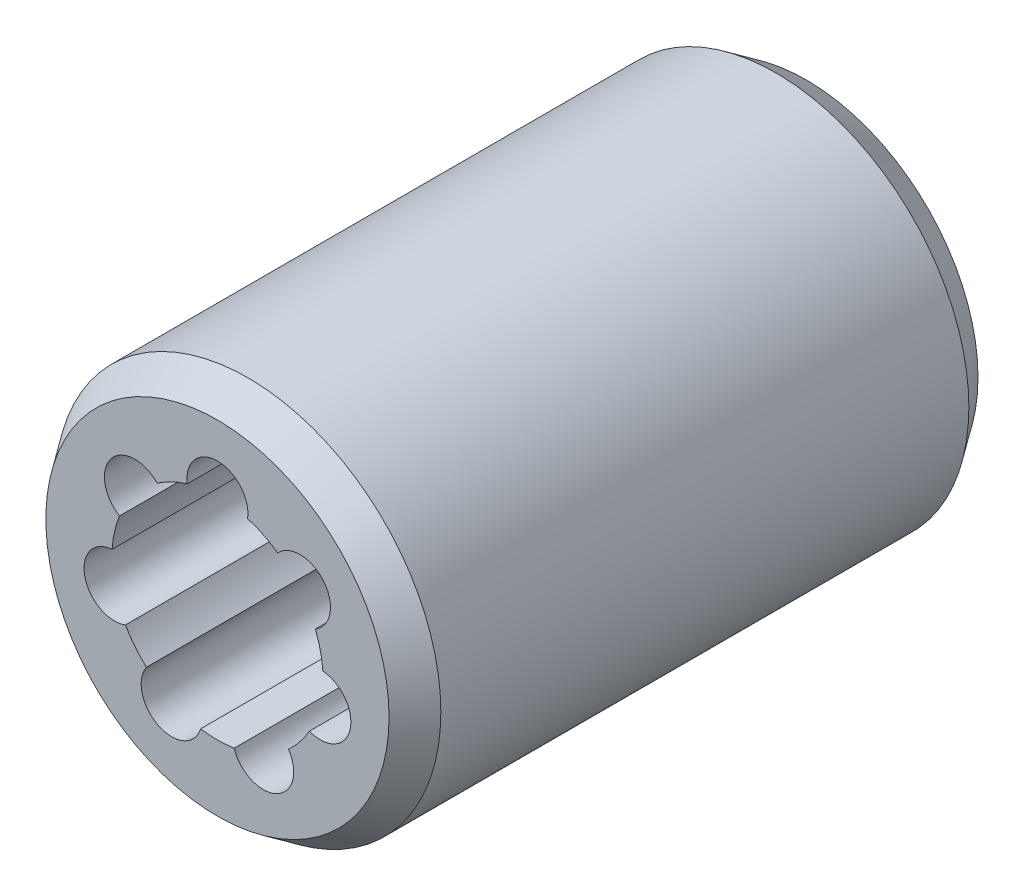
from build123d import *

# Parameters (mm, degrees)
SKETCH1_R           = 9.5
SKETCH1_R_2         = 5.2
BOSS_EXTRUDE1_DEPTH = 29
SKETCH2_R           = 1.5
CUT_EXTRUDE1_DEPTH  = 30
CIRPATTERN1_COUNT   = 7
CHAMFER1_SIZE       = 1.5
CHAMFER1_SIZE2      = 1.050311307


with BuildPart() as part:
    # Sketch1 → Boss-Extrude1 (new body)
    with BuildSketch(Plane.XY):
        Circle(SKETCH1_R)
        Circle(SKETCH1_R_2, mode=Mode.SUBTRACT)
    extrude(amount=BOSS_EXTRUDE1_DEPTH)

    # Sketch2 → Cut-Extrude1 (cut, through all)
    with BuildSketch(Plane.XY.offset(29)):
        with Locations((0, 5.2)):
            Circle(SKETCH2_R)
    cut_extrude1 = extrude(amount=-CUT_EXTRUDE1_DEPTH, mode=Mode.SUBTRACT)

    # CirPattern1: Cut-Extrude1 ×7 about axis
    cirpattern1_axis = Axis((0, 0, 0), (0, 0, 1))
    for i in range(1, CIRPATTERN1_COUNT):
        add(cut_extrude1.rotate(cirpattern1_axis, i * 360 / CIRPATTERN1_COUNT), mode=Mode.SUBTRACT)

    # Chamfer1
    chamfer1_edges = [part.edges().sort_by_distance(p)[0] for p in [
        (-9.5, 0, 0),
        (-9.5, 0, 29),
    ]]
    chamfer1_side = [part.faces().sort_by_distance(p)[0] for p in [
        (-9.5, 0, 14.5),
    ]]
    chamfer(chamfer1_edges, length=CHAMFER1_SIZE, length2=CHAMFER1_SIZE2, reference=chamfer1_side[0])


solid = part.part
